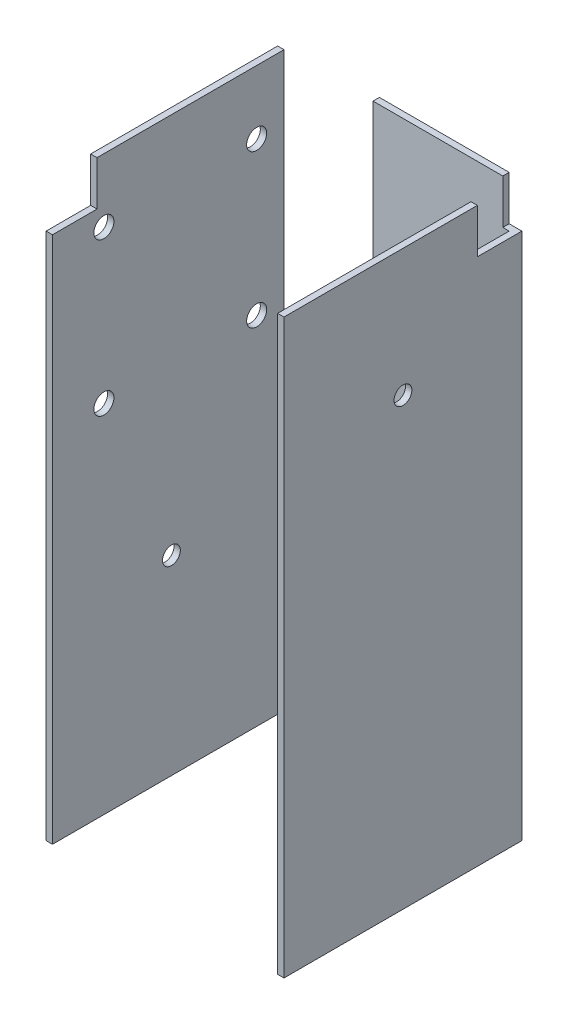
from build123d import *

# Parameters (mm, degrees)
BOSS_EXTRUDE1_DEPTH = 114.3
SKETCH8_R           = 1.778
CUT_EXTRUDE1_DEPTH  = 5.08
SKETCH9_R           = 1.778
CUT_EXTRUDE2_DEPTH  = 5.08
SKETCH10_R          = 1.778
CUT_EXTRUDE3_DEPTH  = 5.08
SKETCH13_R          = 1.778
CUT_EXTRUDE6_DEPTH  = 5.08
CUT_EXTRUDE7_DEPTH  = 2.54
SKETCH16_W          = 19.05
SKETCH16_H          = 1.27
CUT_EXTRUDE8_DEPTH  = 47.625
SKETCH17_W          = 8.89
SKETCH17_H          = 8.89
CUT_EXTRUDE9_DEPTH  = 38.1
SKETCH18_W          = 8.89
SKETCH18_H          = 8.89
CUT_EXTRUDE10_DEPTH = 2.54


with BuildPart() as part:
    # Sketch1 → Boss-Extrude1 (new body)
    with BuildSketch(Plane(origin=(0, 0, 0), x_dir=(1, 0, 0), z_dir=(0, 1, 0))):
        Polygon((23.749, 23.749), (-23.749, 23.749), (-23.749, -23.749), (-22.479, -23.749), (-22.479, 22.479), (22.479, 22.479), (22.479, -23.749), (23.749, -23.749), align=None)
    extrude(amount=BOSS_EXTRUDE1_DEPTH)

    # Sketch8 → Cut-Extrude1 (cut)
    with BuildSketch(Plane(origin=(0, 0, -23.749), x_dir=(-1, 0, 0), z_dir=(0, 0, -1))):
        with Locations((0, 57.15)):
            Circle(SKETCH8_R)
    extrude(amount=-CUT_EXTRUDE1_DEPTH, mode=Mode.SUBTRACT)

    # Sketch9 → Cut-Extrude2 (cut)
    with BuildSketch(Plane.ZY.offset(23.749)):
        with Locations((0, 38.1)):
            Circle(SKETCH9_R)
    extrude(amount=-CUT_EXTRUDE2_DEPTH, mode=Mode.SUBTRACT)

    # Sketch10 → Cut-Extrude3 (cut)
    with BuildSketch(Plane(origin=(23.749, 0, 0), x_dir=(0, 0, -1), z_dir=(1, 0, 0))):
        with Locations((0, 88.9)):
            Circle(SKETCH10_R)
    extrude(amount=-CUT_EXTRUDE3_DEPTH, mode=Mode.SUBTRACT)

    # Sketch13 → Cut-Extrude6 (cut)
    with BuildSketch(Plane(origin=(0, 0, -23.749), x_dir=(-1, 0, 0), z_dir=(0, 0, -1))):
        with Locations((0, 25.4)):
            Circle(SKETCH13_R)
    extrude(amount=-CUT_EXTRUDE6_DEPTH, mode=Mode.SUBTRACT)

    # Sketch14 → Cut-Extrude7 (cut)
    with BuildSketch(Plane.ZY.offset(23.749)):
        with BuildLine():
            Line((-17.018, 99.6), (-17.018, 101.6))
            Line((-17.018, 101.6), (-15.018, 101.6))
            ThreePointArc((-15.018, 101.6), (-18.432213562, 103.014213562), (-17.018, 99.6))
        make_face()
        with BuildLine():
            Line((-15.018, 101.6), (-17.018, 101.6))
            Line((-17.018, 101.6), (-17.018, 99.6))
            ThreePointArc((-17.018, 99.6), (-15.603786438, 100.185786438), (-15.018, 101.6))
        make_face()
        with BuildLine():
            ThreePointArc((15.482, 101.6), (13.482, 103.6), (11.482, 101.6))
            Line((11.482, 101.6), (13.482, 101.6))
            Line((13.482, 101.6), (13.482, 99.6))
            ThreePointArc((13.482, 99.6), (14.896213562, 100.185786438), (15.482, 101.6))
        make_face()
        with BuildLine():
            Line((13.482, 101.6), (11.482, 101.6))
            ThreePointArc((11.482, 101.6), (12.067786438, 100.185786438), (13.482, 99.6))
            Line((13.482, 99.6), (13.482, 101.6))
        make_face()
        with BuildLine():
            ThreePointArc((15.482, 71.1), (14.896213562, 72.514213562), (13.482, 73.1))
            Line((13.482, 73.1), (13.482, 71.1))
            Line((13.482, 71.1), (11.482, 71.1))
            ThreePointArc((11.482, 71.1), (13.482, 69.1), (15.482, 71.1))
        make_face()
        with BuildLine():
            Line((13.482, 71.1), (13.482, 73.1))
            ThreePointArc((13.482, 73.1), (12.067786438, 72.514213562), (11.482, 71.1))
            Line((11.482, 71.1), (13.482, 71.1))
        make_face()
        with BuildLine():
            ThreePointArc((-15.018, 71.1), (-15.603786438, 72.514213562), (-17.018, 73.1))
            Line((-17.018, 73.1), (-17.018, 71.1))
            Line((-17.018, 71.1), (-15.018, 71.1))
        make_face()
        with BuildLine():
            Line((-17.018, 71.1), (-17.018, 73.1))
            ThreePointArc((-17.018, 73.1), (-18.432213562, 69.685786438), (-15.018, 71.1))
            Line((-15.018, 71.1), (-17.018, 71.1))
        make_face()
    extrude(amount=-CUT_EXTRUDE7_DEPTH, mode=Mode.SUBTRACT)

    # Sketch16 → Cut-Extrude8 (cut)
    with BuildSketch(Plane(origin=(0, 114.3, 0), x_dir=(1, 0, 0), z_dir=(0, 1, 0))):
        with Locations((-14.224, 23.114)):
            Rectangle(SKETCH16_W, SKETCH16_H)
    extrude(amount=-CUT_EXTRUDE8_DEPTH, mode=Mode.SUBTRACT)

    # Sketch17 → Cut-Extrude9 (cut)
    with BuildSketch(Plane.ZY.offset(23.749)):
        with Locations((19.304, 109.855)):
            Rectangle(SKETCH17_W, SKETCH17_H)
    extrude(amount=-CUT_EXTRUDE9_DEPTH, mode=Mode.SUBTRACT)

    # Sketch18 → Cut-Extrude10 (cut)
    with BuildSketch(Plane(origin=(23.749, 0, 0), x_dir=(0, 0, -1), z_dir=(1, 0, 0))):
        with Locations((19.304, 109.855)):
            Rectangle(SKETCH18_W, SKETCH18_H)
    extrude(amount=-CUT_EXTRUDE10_DEPTH, mode=Mode.SUBTRACT)


solid = part.part
